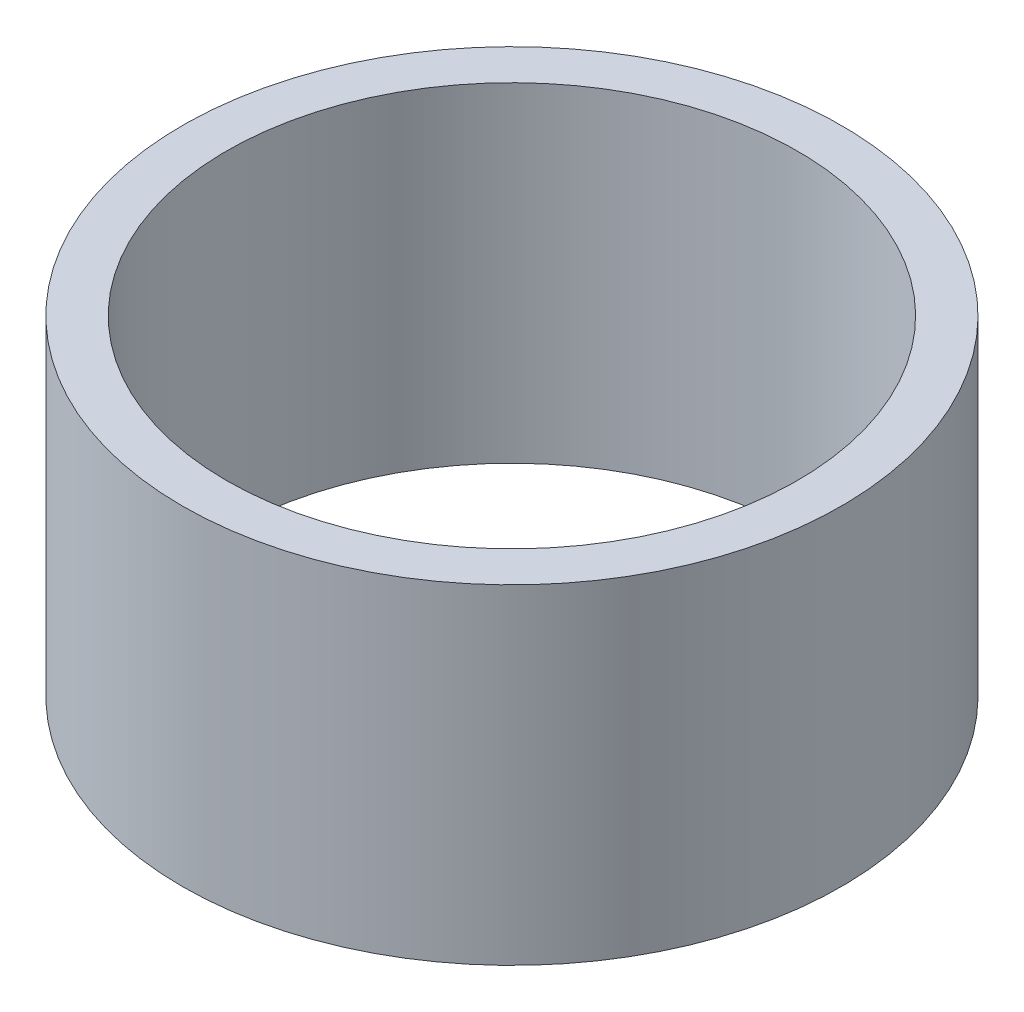
from build123d import *

# Parameters (mm, degrees)
SKETCH1_R           = 12.7
SKETCH1_R_2         = 11
BOSS_EXTRUDE1_DEPTH = 12.7


with BuildPart() as part:
    # Sketch1 → Boss-Extrude1 (new body)
    with BuildSketch(Plane(origin=(0, 0, 0), x_dir=(1, 0, 0), z_dir=(0, 1, 0))):
        Circle(SKETCH1_R)
        Circle(SKETCH1_R_2, mode=Mode.SUBTRACT)
    extrude(amount=BOSS_EXTRUDE1_DEPTH)


solid = part.part
